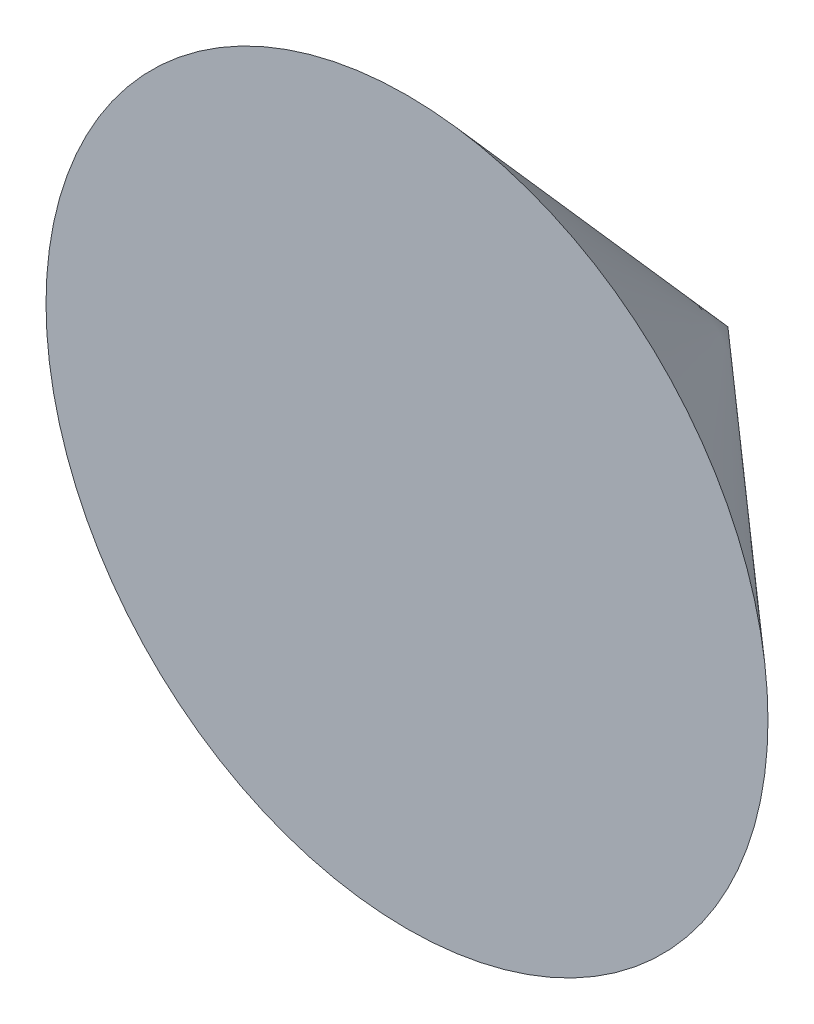
from build123d import *


with BuildPart() as part:
    # Sketch1 → Revolve1 (revolve)
    with BuildSketch(Plane(origin=(0, 0, 0), x_dir=(0, 0, -1), z_dir=(1, 0, 0))):
        Polygon((0, 0), (8, 0), (0, 9), align=None)
    revolve(axis=Axis((0, 0, 0), (0, 0, -1)))


solid = part.part
